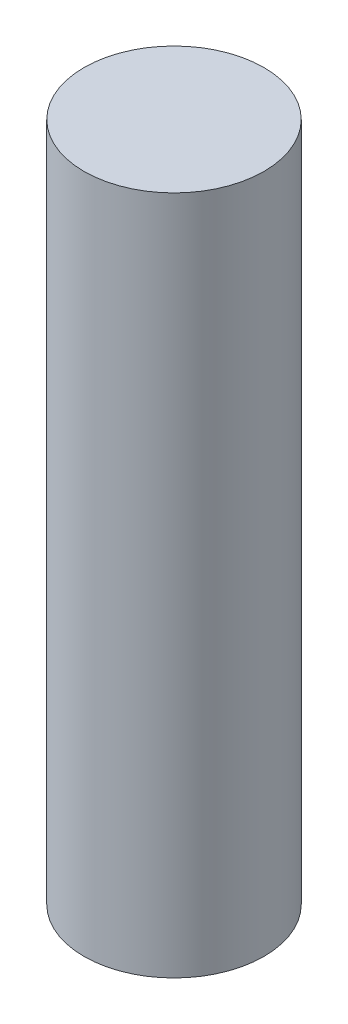
from build123d import *

# Parameters (mm, degrees)
SKETCH_1_W = 9
SKETCH_1_H = 68


with BuildPart() as part:
    # 草图1 → 旋转1 (revolve)
    with BuildSketch(Plane.XY):
        with Locations((74.5, 34)):
            Rectangle(SKETCH_1_W, SKETCH_1_H)
    revolve(axis=Axis((70, 68, 0), (0, -1, 0)))


solid = part.part
